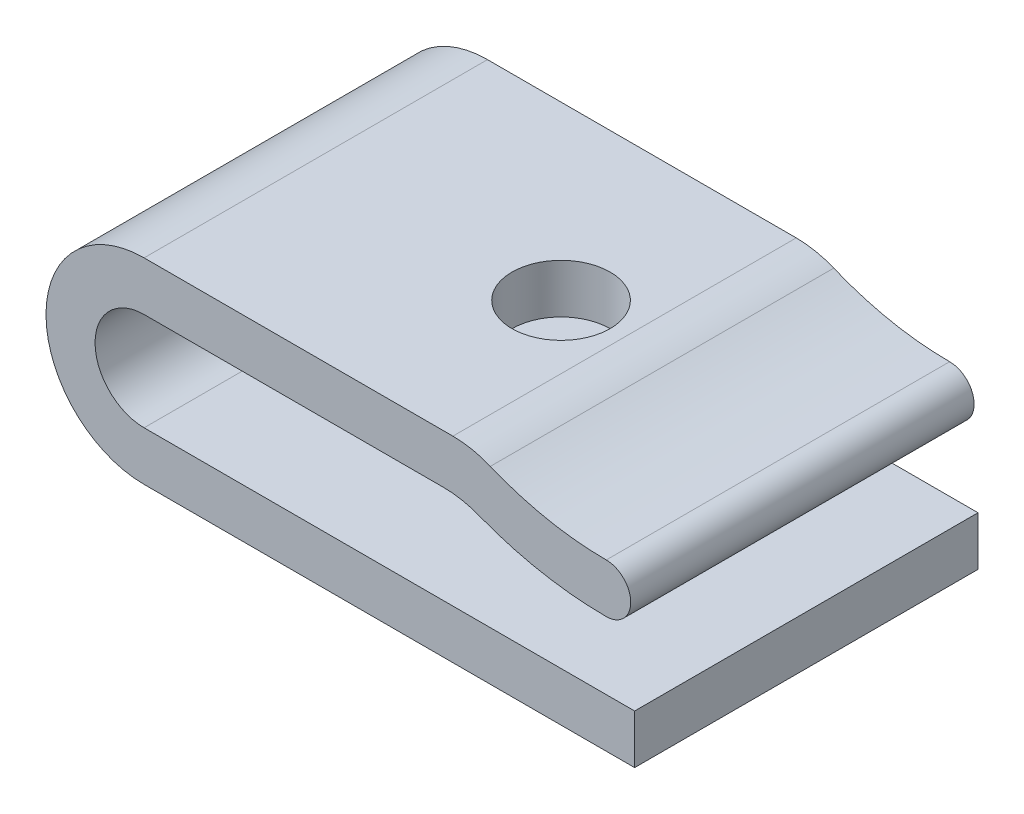
from build123d import *

# Parameters (mm, degrees)
BOSS_EXTRUDE1_DEPTH = 14
SKETCH2_R           = 2
CUT_EXTRUDE2_DEPTH  = 9


with BuildPart() as part:
    # Sketch1 → Boss-Extrude1 (new body)
    with BuildSketch(Plane.XY):
        with BuildLine():
            ThreePointArc((-0.158092835, 3.754907593), (-0.451477513, 3.047309694), (-1.159482409, 2.754908559))
            ThreePointArc((-1.159482409, 2.754908559), (-3.799725402, 3.002497057), (-6.349938035, 3.729544963))
            ThreePointArc((-6.349938035, 3.729544963), (-7.060326346, 3.93180492), (-7.795792236, 4))
            Line((-7.795792236, 4), (-20, 4))
            ThreePointArc((-20, 4), (-22, 2), (-20, 0))
            Line((-20, 0), (0, 0))
            Line((0, 0), (0, -2))
            Line((0, -2), (-20, -2))
            ThreePointArc((-20, -2), (-24, 2), (-20, 6))
            Line((-20, 6), (-7.410531978, 6))
            ThreePointArc((-7.410531978, 6), (-6.631548949, 5.923415023), (-5.882395119, 5.696592721))
            ThreePointArc((-5.882395119, 5.696592721), (-3.565674535, 4.994277462), (-1.156703262, 4.754906628))
            ThreePointArc((-1.156703262, 4.754906628), (-0.450494936, 4.461522915), (-0.158092835, 3.754907593))
        make_face()
    extrude(amount=BOSS_EXTRUDE1_DEPTH)

    # Sketch2 → Cut-Extrude2 (cut, through all)
    with BuildSketch(Plane(origin=(0, -2, 0), x_dir=(-1, 0, 0), z_dir=(0, -1, 0))):
        with Locations((10, -7)):
            Circle(SKETCH2_R)
    extrude(amount=-CUT_EXTRUDE2_DEPTH, mode=Mode.SUBTRACT)


solid = part.part
